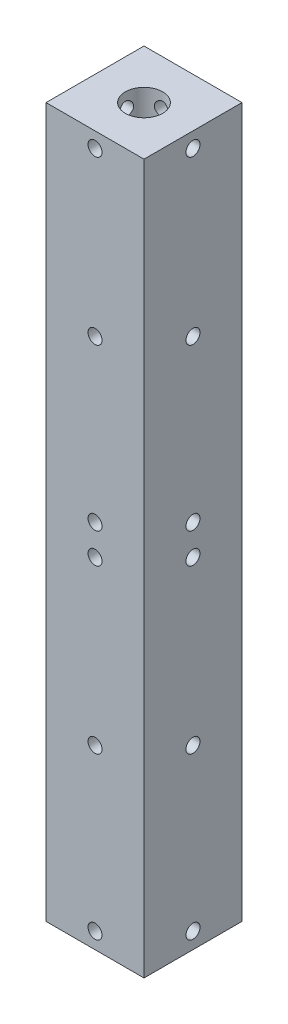
from build123d import *

# Parameters (mm, degrees)
SKETCH1_W                   = 21
SKETCH1_H                   = 21
BOSS_EXTRUDE1_DEPTH         = 152
SKETCH2_R                   = 4
CUT_EXTRUDE1_DEPTH          = 152
LPATTERN1_COUNT             = 2
LPATTERN1_PITCH             = 75.9
CIRPATTERN1_COUNT           = 4
CUT_EXTRUDE2_START          = -6.791901
SKETCH6_R                   = 1.5
CUT_EXTRUDE2_DEPTH          = 6.791901
LPATTERN2_COUNT             = 2
LPATTERN2_PITCH             = 75.9
CIRPATTERN2_COUNT           = 4
CIRPATTERN2_START           = -6.791901
CIRPATTERN2_COPY_1_SKETCH_R = 1.5
CIRPATTERN2_COPY_1_DEPTH    = 6.791901
CIRPATTERN2_COPY_2_SKETCH_R = 1.5
CIRPATTERN2_COPY_2_DEPTH    = 6.791901
CIRPATTERN2_COPY_3_SKETCH_R = 1.5
CIRPATTERN2_COPY_3_DEPTH    = 6.791901


with BuildPart() as part:
    # Sketch1 → Boss-Extrude1 (new body)
    with BuildSketch(Plane(origin=(0, 0, 0), x_dir=(1, 0, 0), z_dir=(0, 1, 0))):
        with Locations((10.5, 10.5)):
            Rectangle(SKETCH1_W, SKETCH1_H)
    extrude(amount=BOSS_EXTRUDE1_DEPTH)

    # Sketch2 → Cut-Extrude1 (cut)
    with BuildSketch(Plane(origin=(0, 152, 0), x_dir=(1, 0, 0), z_dir=(0, 1, 0))):
        with Locations((10.5, 10.5)):
            Circle(SKETCH2_R)
    extrude(amount=-CUT_EXTRUDE1_DEPTH, mode=Mode.SUBTRACT)

    # Sketch5 → Ø3.0mm Dowel Hole1 (revolve, cut)
    with BuildSketch(Plane(origin=(10.5, 37.95, 0), x_dir=(0, -1, 0), z_dir=(1, 0, 0))):
        Polygon((0, 0), (0, 4.901290929), (1.5, 4), (1.5, 0), align=None)
    f_3_0mm_dowel_hole1 = revolve(axis=Axis((10.5, 37.95, 6.35), (0, 0, -1)), mode=Mode.SUBTRACT)

    # LPattern1: Ø3.0mm Dowel Hole1 ×2
    with Locations(*[(0, i * LPATTERN1_PITCH, 0) for i in range(1, LPATTERN1_COUNT)]):
        add(f_3_0mm_dowel_hole1, mode=Mode.SUBTRACT)

    # CirPattern1: Ø3.0mm Dowel Hole1 ×4 about axis
    cirpattern1_axis = Axis((10.5, 0, -10.5), (0, 1, 0))
    for i in range(1, CIRPATTERN1_COUNT):
        add(f_3_0mm_dowel_hole1.rotate(cirpattern1_axis, i * 360 / CIRPATTERN1_COUNT), mode=Mode.SUBTRACT)

    # CirPattern1 copy 1 sketch → CirPattern1 copy 1 (revolve, cut)
    with BuildSketch(Plane(origin=(21, 113.85, -10.5), x_dir=(0, -1, 0), z_dir=(0, 0, -1))):
        Polygon((0, 0), (0, 4.901290929), (1.5, 4), (1.5, 0), align=None)
    revolve(axis=Axis((27.35, 113.85, -10.5), (-1, 0, 0)), mode=Mode.SUBTRACT)

    # CirPattern1 copy 2 sketch → CirPattern1 copy 2 (revolve, cut)
    with BuildSketch(Plane(origin=(10.5, 113.85, -21), x_dir=(0, -1, 0), z_dir=(-1, 0, 0))):
        Polygon((0, 0), (0, 4.901290929), (1.5, 4), (1.5, 0), align=None)
    revolve(axis=Axis((10.5, 113.85, -27.35), (0, 0, 1)), mode=Mode.SUBTRACT)

    # CirPattern1 copy 3 sketch → CirPattern1 copy 3 (revolve, cut)
    with BuildSketch(Plane(origin=(0, 113.85, -10.5), x_dir=(0, -1, 0), z_dir=(0, 0, 1))):
        Polygon((0, 0), (0, 4.901290929), (1.5, 4), (1.5, 0), align=None)
    revolve(axis=Axis((-6.35, 113.85, -10.5), (1, 0, 0)), mode=Mode.SUBTRACT)

    # Sketch6 → Cut-Extrude2 (cut)
    with BuildSketch(Plane.XY.offset(CUT_EXTRUDE2_START)):
        with Locations((10.5, 148.75)):
            Circle(SKETCH6_R)
        with Locations((10.5, 79.35)):
            Circle(SKETCH6_R)
    cut_extrude2 = extrude(amount=CUT_EXTRUDE2_DEPTH, mode=Mode.SUBTRACT)

    # LPattern2: Cut-Extrude2 ×2
    with Locations(*[(0, -i * LPATTERN2_PITCH, 0) for i in range(1, LPATTERN2_COUNT)]):
        add(cut_extrude2, mode=Mode.SUBTRACT)

    # CirPattern2: Cut-Extrude2 ×4 about axis
    cirpattern2_axis = Axis((10.5, 0, -10.5), (0, 1, 0))
    for i in range(1, CIRPATTERN2_COUNT):
        add(cut_extrude2.rotate(cirpattern2_axis, i * 360 / CIRPATTERN2_COUNT), mode=Mode.SUBTRACT)

    # CirPattern2 copy 1 sketch → CirPattern2 copy 1 (cut)
    with BuildSketch(Plane(origin=(21, -75.9, 0), x_dir=(0, 0, -1), z_dir=(1, 0, 0)).offset(CIRPATTERN2_START)):
        with Locations((10.5, 148.75)):
            Circle(CIRPATTERN2_COPY_1_SKETCH_R)
        with Locations((10.5, 79.35)):
            Circle(CIRPATTERN2_COPY_1_SKETCH_R)
    extrude(amount=CIRPATTERN2_COPY_1_DEPTH, mode=Mode.SUBTRACT)

    # CirPattern2 copy 2 sketch → CirPattern2 copy 2 (cut)
    with BuildSketch(Plane(origin=(21, -75.9, -21), x_dir=(-1, 0, 0), z_dir=(0, 0, -1)).offset(CIRPATTERN2_START)):
        with Locations((10.5, 148.75)):
            Circle(CIRPATTERN2_COPY_2_SKETCH_R)
        with Locations((10.5, 79.35)):
            Circle(CIRPATTERN2_COPY_2_SKETCH_R)
    extrude(amount=CIRPATTERN2_COPY_2_DEPTH, mode=Mode.SUBTRACT)

    # CirPattern2 copy 3 sketch → CirPattern2 copy 3 (cut)
    with BuildSketch(Plane(origin=(0, -75.9, -21), x_dir=(0, 0, 1), z_dir=(-1, 0, 0)).offset(CIRPATTERN2_START)):
        with Locations((10.5, 148.75)):
            Circle(CIRPATTERN2_COPY_3_SKETCH_R)
        with Locations((10.5, 79.35)):
            Circle(CIRPATTERN2_COPY_3_SKETCH_R)
    extrude(amount=CIRPATTERN2_COPY_3_DEPTH, mode=Mode.SUBTRACT)


solid = part.part
